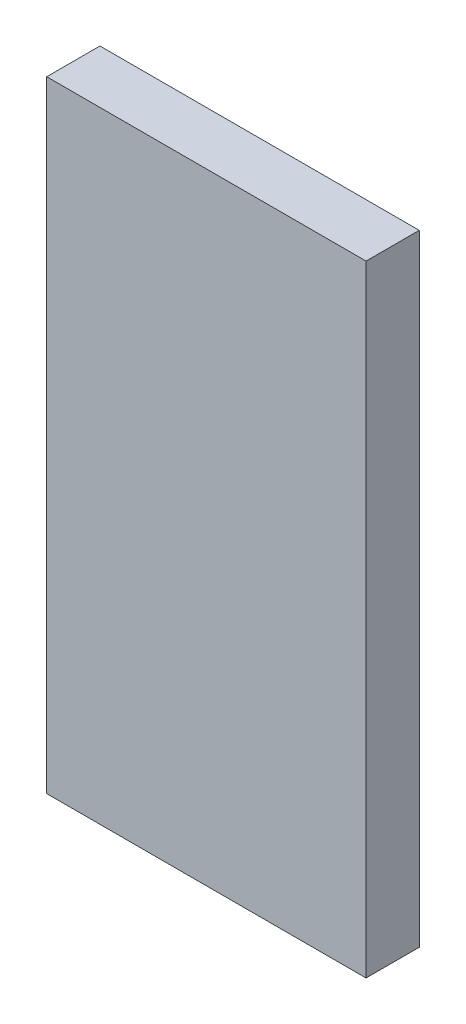
from build123d import *

# Parameters (mm, degrees)
SKETCH1_W           = 18
SKETCH1_H           = 35
BOSS_EXTRUDE1_DEPTH = 3


with BuildPart() as part:
    # Sketch1 → Boss-Extrude1 (new body)
    with BuildSketch(Plane.XY):
        with Locations((9, 17.5)):
            Rectangle(SKETCH1_W, SKETCH1_H)
    extrude(amount=BOSS_EXTRUDE1_DEPTH)


solid = part.part
